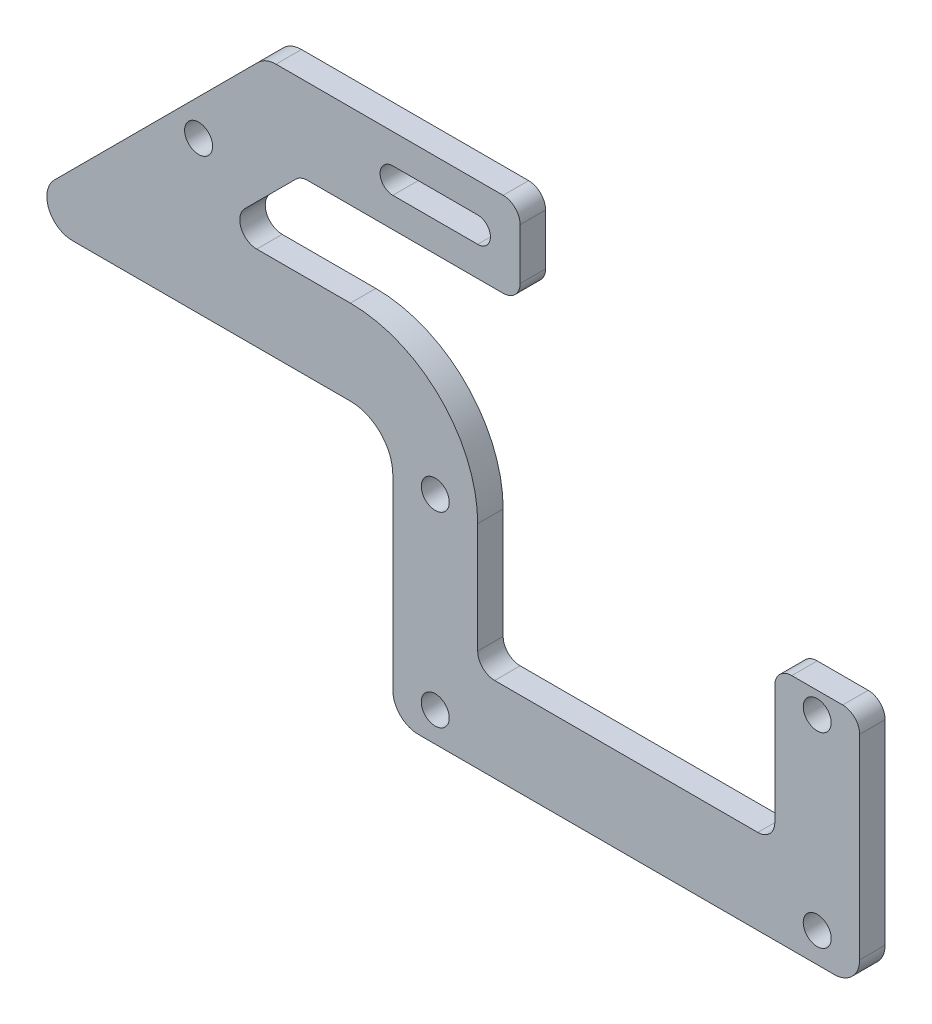
from build123d import *

# Parameters (mm, degrees)
SKETCH_1_W          = 55
SKETCH_1_H          = 30
SKETCH_1_R          = 1.65
EXTRUDE_1_DEPTH     = 3
SKETCH_2_W          = 55
SKETCH_2_H          = 30
EXTRUDE_2_DEPTH     = 3
EXTRUDE_3_DEPTH     = 3
SKETCH_8_R          = 1.65
CUT_EXTRUDE_1_DEPTH = 10
FILLET_1_R          = 5
FILLET_2_R          = 3
CUT_EXTRUDE_2_DEPTH = 10
CUT_EXTRUDE_3_DEPTH = 4
CUT_EXTRUDE_4_DEPTH = 4
FILLET_3_R          = 2


with BuildPart() as part:
    # 草图1 → 凸台-拉伸1 (new body)
    with BuildSketch(Plane.XY):
        with Locations((0, 11.5)):
            Rectangle(SKETCH_1_W, SKETCH_1_H)
        with Locations((-22.5, 0)):
            Circle(SKETCH_1_R, mode=Mode.SUBTRACT)
        with Locations((-22.5, 22)):
            Circle(SKETCH_1_R, mode=Mode.SUBTRACT)
        with Locations((22.5, 22)):
            Circle(SKETCH_1_R, mode=Mode.SUBTRACT)
        with Locations((22.5, 0)):
            Circle(SKETCH_1_R, mode=Mode.SUBTRACT)
    extrude(amount=EXTRUDE_1_DEPTH)

    # 草图2 → 凸台-拉伸2 (add)
    with BuildSketch(Plane.XY.offset(3)):
        with Locations((0, 41.5)):
            Rectangle(SKETCH_2_W, SKETCH_2_H)
    extrude(amount=-EXTRUDE_2_DEPTH)

    # 草图4 → 凸台-拉伸3 (add)
    with BuildSketch(Plane.XY.offset(3)):
        Polygon((-27.5, 26.5), (-72.5, 26.5), (-42.5, 56.5), (-27.5, 56.5), align=None)
    extrude(amount=-EXTRUDE_3_DEPTH)

    # 草图8 → 切除-拉伸1 (cut)
    with BuildSketch(Plane(origin=(0, 0, 0), x_dir=(-1, 0, 0), z_dir=(0, 0, -1))):
        with Locations((50.378679656, 44.378679656)):
            Circle(SKETCH_8_R)
    extrude(amount=-CUT_EXTRUDE_1_DEPTH, mode=Mode.SUBTRACT)

    # 圆角1
    fillet_1_edges = [part.edges().sort_by_distance(p)[0] for p in [
        (-27.5, 26.5, 1.5),
    ]]
    fillet(fillet_1_edges, radius=FILLET_1_R)

    # 圆角2
    fillet_2_edges = [part.edges().sort_by_distance(p)[0] for p in [
        (27.5, 56.5, 1.5),
        (-42.5, 56.5, 1.5),
        (-72.5, 26.5, 1.5),
        (27.5, -3.5, 1.5),
        (-27.5, -3.5, 1.5),
    ]]
    fillet(fillet_2_edges, radius=FILLET_2_R)

    # 草图9 → 切除-拉伸2 (cut)
    with BuildSketch(Plane(origin=(0, 0, 0), x_dir=(-1, 0, 0), z_dir=(0, 0, -1))):
        with BuildLine():
            Line((17.5, 53), (27.5, 53))
            ThreePointArc((27.5, 53), (29, 51.5), (27.5, 50))
            Line((27.5, 50), (17.5, 50))
            ThreePointArc((17.5, 50), (16, 51.5), (17.5, 53))
        make_face()
    extrude(amount=-CUT_EXTRUDE_2_DEPTH, mode=Mode.SUBTRACT)

    # 草图10 → 切除-拉伸3 (cut, through all)
    with BuildSketch(Plane(origin=(0, 0, 0), x_dir=(-1, 0, 0), z_dir=(0, 0, -1))):
        with BuildLine():
            Line((-15.5, 6.5), (15.5, 6.5))
            ThreePointArc((15.5, 6.5), (16.914213562, 7.085786438), (17.5, 8.5))
            Line((17.5, 8.5), (17.5, 21.5))
            ThreePointArc((17.5, 21.5), (21.893398282, 32.106601718), (32.5, 36.5))
            Line((32.5, 36.5), (43.529437252, 36.5))
            ThreePointArc((43.529437252, 36.5), (45.377196317, 37.734633135), (44.943650814, 39.914213562))
            Line((44.943650814, 39.914213562), (38.943650814, 45.914213562))
            ThreePointArc((38.943650814, 45.914213562), (38.294804116, 46.347759065), (37.529437252, 46.5))
            Line((37.529437252, 46.5), (-15.5, 46.5))
            ThreePointArc((-15.5, 46.5), (-16.914213562, 45.914213562), (-17.5, 44.5))
            Line((-17.5, 44.5), (-17.5, 8.5))
            ThreePointArc((-17.5, 8.5), (-16.914213562, 7.085786438), (-15.5, 6.5))
        make_face()
    extrude(amount=-CUT_EXTRUDE_3_DEPTH, mode=Mode.SUBTRACT)

    # 草图11 → 切除-拉伸4 (cut, through all)
    with BuildSketch(Plane(origin=(0, 0, 0), x_dir=(-1, 0, 0), z_dir=(0, 0, -1))):
        with BuildLine():
            Line((-27.5, 24.5), (12.5, 24.5))
            Line((12.5, 24.5), (12.5, 56.5))
            Line((12.5, 56.5), (-24.5, 56.5))
            ThreePointArc((-24.5, 56.5), (-26.621320344, 55.621320344), (-27.5, 53.5))
            Line((-27.5, 53.5), (-27.5, 24.5))
        make_face()
    extrude(amount=-CUT_EXTRUDE_4_DEPTH, mode=Mode.SUBTRACT)

    # 圆角3
    fillet_3_edges = [part.edges().sort_by_distance(p)[0] for p in [
        (-12.5, 46.5, 1.5),
        (17.5, 24.5, 1.5),
        (-12.5, 56.5, 1.5),
        (27.5, 24.5, 1.5),
    ]]
    fillet(fillet_3_edges, radius=FILLET_3_R)


solid = part.part
